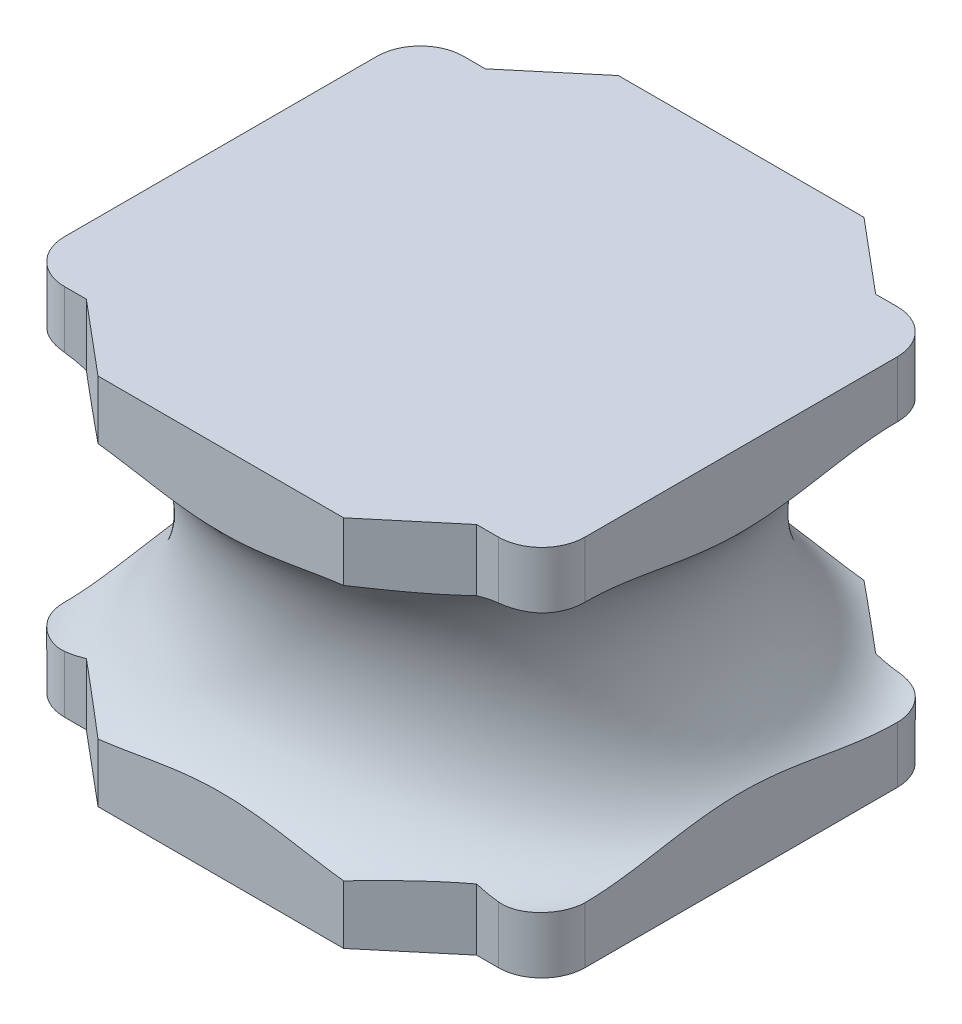
from build123d import *

# Parameters (mm, degrees)
BOSS_EXTRUDE1_DEPTH = 4.3
SKETCH2_RX          = 1.5
SKETCH2_RY          = 1


with BuildPart() as part:
    # Sketch1 → Boss-Extrude1 (new body)
    with BuildSketch(Plane(origin=(0, 0, 0), x_dir=(1, 0, 0), z_dir=(0, 1, 0))):
        with BuildLine():
            Line((-1.415772485, -3), (1.415772485, -3))
            Line((1.415772485, -3), (2.25, -2.3))
            Line((2.25, -2.3), (2.5, -2.3))
            ThreePointArc((2.5, -2.3), (2.853553391, -2.153553391), (3, -1.8))
            Line((3, -1.8), (3, 1.8))
            ThreePointArc((3, 1.8), (2.853553391, 2.153553391), (2.5, 2.3))
            Line((2.5, 2.3), (2.25, 2.3))
            Line((2.25, 2.3), (1.415772485, 3))
            Line((1.415772485, 3), (-1.415772485, 3))
            Line((-1.415772485, 3), (-2.25, 2.3))
            Line((-2.25, 2.3), (-2.5, 2.3))
            ThreePointArc((-2.5, 2.3), (-2.853553391, 2.153553391), (-3, 1.8))
            Line((-3, 1.8), (-3, -1.8))
            ThreePointArc((-3, -1.8), (-2.853553391, -2.153553391), (-2.5, -2.3))
            Line((-2.5, -2.3), (-2.25, -2.3))
            Line((-2.25, -2.3), (-1.415772485, -3))
        make_face()
    extrude(amount=BOSS_EXTRUDE1_DEPTH)

    # Sketch2 → Cut-Revolve1 (revolve, cut)
    with BuildSketch(Plane.XY):
        with Locations(Location((3.5, 2.15), (0, 0, 90))):
            Ellipse(SKETCH2_RX, SKETCH2_RY)
    revolve(axis=Axis((0, 0, 0), (0, 1, 0)), mode=Mode.SUBTRACT)


solid = part.part
